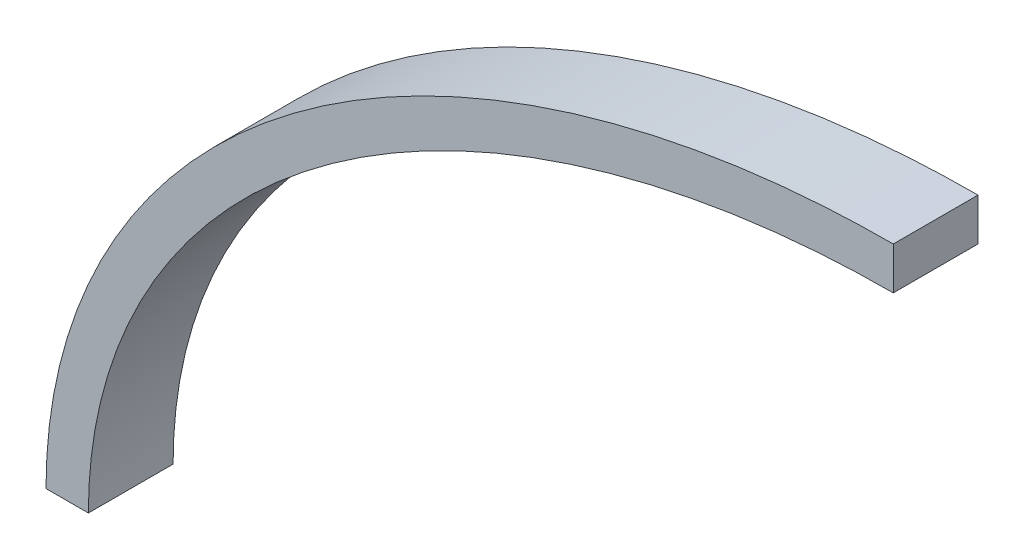
from build123d import *

# Parameters (mm, degrees)
BOSS_EXTRUDE1_DEPTH = 10


with BuildPart() as part:
    # Sketch2 → Boss-Extrude1 (new body)
    with BuildSketch(Plane.XY):
        with BuildLine():
            Line((0, 75), (0, 70))
            add(Edge.make_bspline(
                [(-95, 0), (-95, 4.488262684), (-93.827990877, 13.410482024), (-88.575709321, 26.430951058), (-79.935790359, 38.569652718), (-68.16305415, 49.340914617), (-53.676061754, 58.264740348), (-37.034105075, 64.940810437), (-21.920151322, 68.38050347), (-9.450732761, 69.767803841), (-3.146591781, 70), (0, 70)],
                knots=[1.570796327, 1.570796327, 1.570796327, 1.570796327, 1.767145868, 1.963495408, 2.159844949, 2.35619449, 2.552544031, 2.748893572, 2.945243113, 3.043417883, 3.141592654, 3.141592654, 3.141592654, 3.141592654], degree=3))
            Line((-95, 0), (-100, 0))
            add(Edge.make_bspline(
                [(0, 75), (-100, 75), (-100, 0)],
                knots=[1.570796327, 1.570796327, 1.570796327, 3.141592654, 3.141592654, 3.141592654], degree=2, weights=[1, 0.707106781, 1]))
        make_face()
    extrude(amount=BOSS_EXTRUDE1_DEPTH)


solid = part.part
